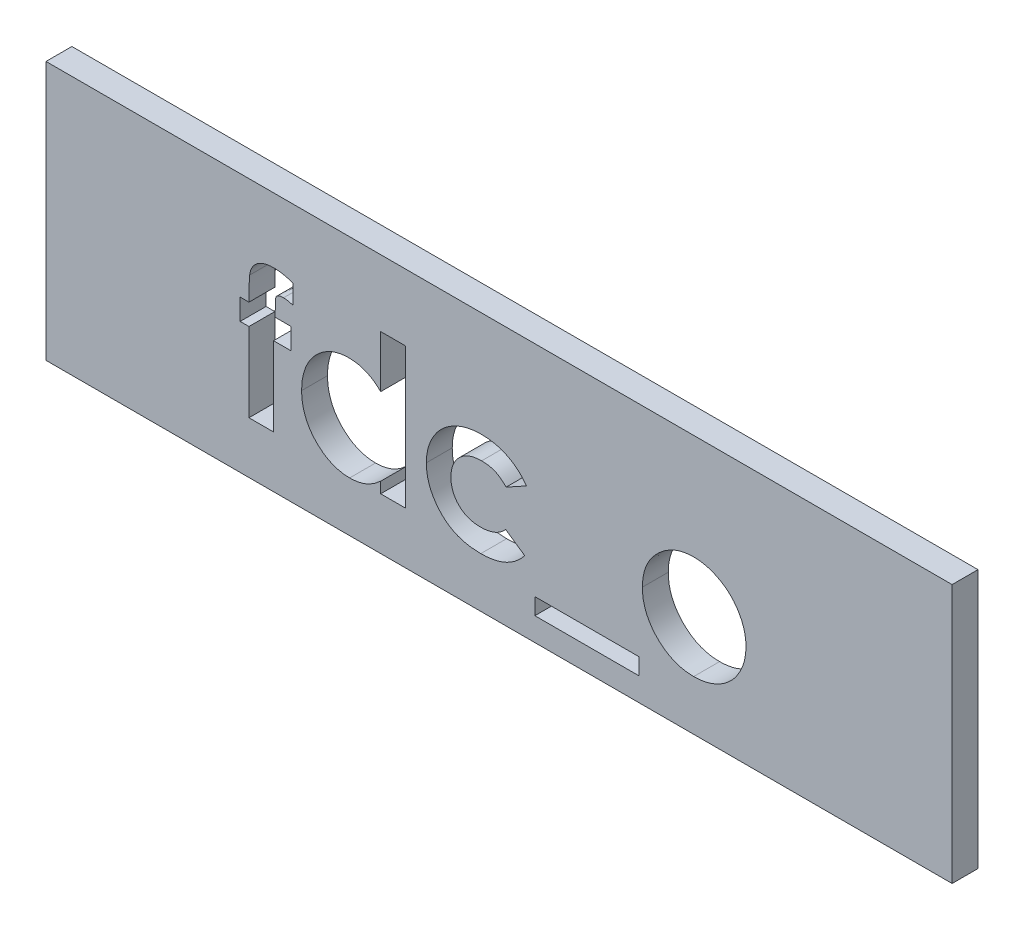
from build123d import *

# Parameters (mm, degrees)
ESQUISSE1_W             = 35
ESQUISSE1_H             = 10
BOSS_EXTRU_1_DEPTH      = 1
ESQUISSE2_R             = 1
BOSS_EXTRU_2_DEPTH      = 3
CHANFREIN1_SIZE         = 0.5
ESQUISSE3_W             = 3.731303419
ESQUISSE3_H             = 0.339209402
ENL_V_MAT_EXTRU_2_DEPTH = 1
ESQUISSE4_W             = 4.031303419
ESQUISSE4_H             = 0.639209402
ENL_V_MAT_EXTRU_3_DEPTH = 5


with BuildPart() as part:
    # Esquisse1 → Boss.-Extru.1 (new body)
    with BuildSketch(Plane.XY):
        with Locations((17.5, -5)):
            Rectangle(ESQUISSE1_W, ESQUISSE1_H)
    extrude(amount=BOSS_EXTRU_1_DEPTH)

    # Esquisse2 → Boss.-Extru.2 (add)
    with BuildSketch(Plane(origin=(0, 0, 0), x_dir=(-1, 0, 0), z_dir=(0, 0, -1))):
        with Locations(Location((-30, -5, 0), (0, 0, 180))):  # turned: the seam where the file's is
            Circle(ESQUISSE2_R)
        with Locations(Location((-5, -5, 0), (0, 0, 180))):  # turned: the seam where the file's is
            Circle(ESQUISSE2_R)
    extrude(amount=BOSS_EXTRU_2_DEPTH)

    # Chanfrein1
    chanfrein1_edges = [part.edges().sort_by_distance(p)[0] for p in [
        (29, -5, -3),
        (4, -5, -3),
    ]]
    chamfer(chanfrein1_edges, length=CHANFREIN1_SIZE)

    # Esquisse3 → Enlèv. mat.-Extru.2 (cut)
    with BuildSketch(Plane.XY.offset(1)):
        with BuildLine():
            Line((7.5, -4.133012821), (7.839209402, -4.133012821))
            add(Edge.make_bspline(
                [(7.839209402, -4.133012821), (7.839436087, -4.071529895), (7.839864718, -3.955274043), (7.842396141, -3.790623415), (7.844103204, -3.645738514), (7.847152395, -3.520641627), (7.851443807, -3.415699183), (7.855842957, -3.330916919), (7.859138216, -3.265759909), (7.863784094, -3.229146271), (7.865710136, -3.213967348)],
                knots=[0, 0, 0, 0, 1.604323161, 3.033556972, 4.296844687, 5.385167547, 6.298701784, 7.037230881, 7.60086462, 8, 8, 8, 8], degree=3))
            add(Edge.make_bspline(
                [(7.865710136, -3.213967348), (7.87474158, -3.161890377), (7.892346922, -3.060374738), (7.950626286, -2.918882495), (8.035310899, -2.795626552), (8.125081789, -2.708625992), (8.20827639, -2.649232911), (8.278069746, -2.610441166), (8.353957303, -2.577184782), (8.436184252, -2.551107791), (8.523968561, -2.529806224), (8.618257573, -2.514998431), (8.718533988, -2.506838038), (8.787567862, -2.505495261), (8.822916667, -2.504807692)],
                knots=[0, 0, 0, 0, 1.43722947, 2.801646624, 4.13175475, 5.486897933, 6.18427957, 6.91287343, 7.658885333, 8.438447905, 9.260561323, 10.118602268, 11.036630026, 12, 12, 12, 12], degree=3))
            add(Edge.make_bspline(
                [(8.822916667, -2.504807692), (8.877076848, -2.506497842), (8.989881613, -2.510018085), (9.163196958, -2.538477083), (9.347072447, -2.582043201), (9.470865215, -2.622584077), (9.53525641, -2.643671541)],
                knots=[0, 0, 0, 0, 0.891275659, 1.856347963, 2.884972697, 4, 4, 4, 4], degree=3))
            Line((9.53525641, -2.643671541), (9.53525641, -3.382512019))
            add(Edge.make_bspline(
                [(9.53525641, -3.382512019), (9.500719238, -3.372963073), (9.434849131, -3.354751099), (9.340072483, -3.33453419), (9.254675848, -3.322050298), (9.201027756, -3.319911685), (9.17590645, -3.318910256)],
                knots=[0, 0, 0, 0, 1.174725213, 2.24046353, 3.176077791, 4, 4, 4, 4], degree=3))
            add(Edge.make_bspline(
                [(9.17590645, -3.318910256), (9.148258685, -3.319492882), (9.096451036, -3.320584631), (9.024638093, -3.334473818), (8.963150903, -3.35634296), (8.931258279, -3.381319103), (8.916199252, -3.393112313)],
                knots=[0, 0, 0, 0, 1.199997209, 2.248609783, 3.173030359, 4, 4, 4, 4], degree=3))
            add(Edge.make_bspline(
                [(8.916199252, -3.393112313), (8.907086663, -3.404752874), (8.886953978, -3.430470677), (8.868654658, -3.482949523), (8.859364297, -3.549278153), (8.85773195, -3.598364775), (8.856837607, -3.625258747)],
                knots=[0, 0, 0, 0, 0.721105823, 1.593158367, 2.681320256, 4, 4, 4, 4], degree=3))
            Line((8.856837607, -3.625258747), (8.853657519, -4.133012821))
            Line((8.853657519, -4.133012821), (9.46741453, -4.133012821))
            Line((9.46741453, -4.133012821), (9.46741453, -4.947115385))
            Line((9.46741453, -4.947115385), (8.788995726, -4.947115385))
            Line((8.788995726, -4.947115385), (8.788995726, -8))
            Line((8.788995726, -8), (7.839209402, -8))
            Line((7.839209402, -8), (7.839209402, -4.947115385))
            Line((7.839209402, -4.947115385), (7.5, -4.947115385))
            Line((7.5, -4.947115385), (7.5, -4.133012821))
        make_face()
        with BuildLine():
            Line((12.927350427, -2.572649573), (13.877136752, -2.572649573))
            Line((13.877136752, -2.572649573), (13.877136752, -8))
            Line((13.877136752, -8), (12.927350427, -8))
            Line((12.927350427, -8), (12.927350427, -7.578108307))
            add(Edge.make_bspline(
                [(12.927350427, -7.578108307), (12.880288865, -7.619174794), (12.788951666, -7.698876735), (12.645033795, -7.802292031), (12.50069538, -7.887596284), (12.35524287, -7.955536469), (12.206440721, -8.005703304), (12.053217618, -8.042025263), (11.893366984, -8.063445212), (11.784702726, -8.066361058), (11.729517228, -8.06784188)],
                knots=[0, 0, 0, 0, 1.129196829, 2.191548051, 3.199897424, 4.157751732, 5.089409408, 6.034969131, 7.002052659, 8, 8, 8, 8], degree=3))
            add(Edge.make_bspline(
                [(11.729517228, -8.06784188), (11.667569052, -8.06644824), (11.545155948, -8.063694328), (11.365528306, -8.034704961), (11.19207996, -7.990330274), (11.024951702, -7.927534544), (10.864447606, -7.84616359), (10.709339329, -7.748340493), (10.562285899, -7.630631076), (10.422063147, -7.498128327), (10.293676037, -7.35237436), (10.181438813, -7.195392221), (10.086831175, -7.029408354), (10.0093242, -6.854973072), (9.948354954, -6.672214402), (9.904892607, -6.480552687), (9.879249772, -6.279919477), (9.876075911, -6.143255992), (9.874465812, -6.073926616)],
                knots=[0, 0, 0, 0, 0.980476535, 1.937477201, 2.874147792, 3.812856188, 4.758993464, 5.720109578, 6.712210464, 7.737600662, 8.772720504, 9.783789959, 10.789002326, 11.793715968, 12.802552247, 13.835794126, 14.902098527, 16, 16, 16, 16], degree=3))
            add(Edge.make_bspline(
                [(9.874465812, -6.073926616), (9.876155617, -6.002135956), (9.879470358, -5.861310578), (9.90371749, -5.654656032), (9.946377794, -5.458242081), (10.004548184, -5.271796664), (10.079374291, -5.09528757), (10.17050749, -4.928425622), (10.279187562, -4.771646968), (10.404422078, -4.627620093), (10.539644597, -4.495612504), (10.684308787, -4.380689431), (10.836152417, -4.283056932), (10.995336846, -4.203350925), (11.161839343, -4.141758156), (11.335002559, -4.096728813), (11.515595215, -4.069709626), (11.638616397, -4.0666964), (11.700896434, -4.06517094)],
                knots=[0, 0, 0, 0, 1.136281865, 2.228943489, 3.287578264, 4.313574083, 5.316051562, 6.317280042, 7.318008486, 8.329309503, 9.333984563, 10.305318864, 11.248632312, 12.186624717, 13.117503092, 14.05354244, 15.014596925, 16, 16, 16, 16], degree=3))
            add(Edge.make_bspline(
                [(11.700896434, -4.06517094), (11.758550736, -4.067000128), (11.872562121, -4.070617348), (12.040976575, -4.093386845), (12.203023264, -4.136259821), (12.360670242, -4.191498499), (12.511870158, -4.265830917), (12.657435343, -4.355121947), (12.797749337, -4.460505562), (12.883603923, -4.542000318), (12.927350427, -4.583525307)],
                knots=[0, 0, 0, 0, 1.011899165, 2.001030639, 2.974036179, 3.948778736, 4.92769327, 5.924124564, 6.942254589, 8, 8, 8, 8], degree=3))
            Line((12.927350427, -4.583525307), (12.927350427, -2.572649573))
        make_face()
        with BuildLine():
            Line((18.558226496, -4.921674679), (17.771684696, -5.354166667))
            add(Edge.make_bspline(
                [(17.771684696, -5.354166667), (17.735632486, -5.318063555), (17.666331076, -5.248664299), (17.555200694, -5.16081585), (17.446056067, -5.088079778), (17.334397613, -5.034404293), (17.219227237, -4.993981508), (17.096390884, -4.96720861), (16.964454838, -4.949579608), (16.873194524, -4.947953728), (16.826138488, -4.947115385)],
                knots=[0, 0, 0, 0, 1.150764855, 2.212059359, 3.192108068, 4.105322427, 5.000809612, 5.941206042, 6.938435785, 8, 8, 8, 8], degree=3))
            add(Edge.make_bspline(
                [(16.826138488, -4.947115385), (16.782984856, -4.948157704), (16.698536815, -4.950197436), (16.575144827, -4.965432834), (16.457873387, -4.989361835), (16.346933003, -5.024370047), (16.242521271, -5.0706178), (16.143774752, -5.12534506), (16.051653001, -5.190689399), (15.967458185, -5.265721963), (15.891457566, -5.348331153), (15.823661135, -5.436437405), (15.768119848, -5.531347754), (15.720100961, -5.630831462), (15.684796889, -5.736757056), (15.658967572, -5.848163371), (15.644245101, -5.965055344), (15.642112075, -6.044912531), (15.641025641, -6.085586939)],
                knots=[0, 0, 0, 0, 1.121765476, 2.195200973, 3.227634963, 4.230038321, 5.213228299, 6.192116585, 7.160777141, 8.14345191, 9.118668839, 10.075979138, 11.027630062, 11.972829041, 12.943187208, 13.923755399, 14.94248691, 16, 16, 16, 16], degree=3))
            add(Edge.make_bspline(
                [(15.641025641, -6.085586939), (15.642173552, -6.125199879), (15.64441493, -6.202546952), (15.658185201, -6.316188233), (15.682090908, -6.424369883), (15.717934388, -6.526519978), (15.760896806, -6.623580196), (15.814849737, -6.714778598), (15.878295413, -6.800513425), (15.951567847, -6.880039516), (16.032735111, -6.951563477), (16.120239785, -7.01472654), (16.213820792, -7.068277132), (16.314568258, -7.110302311), (16.420839596, -7.144544041), (16.533344489, -7.168925493), (16.651963215, -7.182458885), (16.732822598, -7.184733534), (16.774197049, -7.185897436)],
                knots=[0, 0, 0, 0, 1.070556293, 2.090336998, 3.088792742, 4.058148387, 5.011235098, 5.952916408, 6.915475435, 7.888633318, 8.869583867, 9.83422472, 10.800707077, 11.776204622, 12.778807041, 13.814557445, 14.881744048, 16, 16, 16, 16], degree=3))
            add(Edge.make_bspline(
                [(16.774197049, -7.185897436), (16.825138914, -7.184731737), (16.924570033, -7.182456462), (17.069114024, -7.163158313), (17.205127942, -7.131245961), (17.332626211, -7.08707673), (17.451430457, -7.029324638), (17.561235423, -6.958784767), (17.6631699, -6.875977477), (17.722612472, -6.811419049), (17.752604167, -6.778846154)],
                knots=[0, 0, 0, 0, 1.116373375, 2.178998604, 3.189797796, 4.174590301, 5.13072713, 6.078291395, 7.030403691, 8, 8, 8, 8], degree=3))
            Line((17.752604167, -6.778846154), (18.490384615, -7.285540198))
            add(Edge.make_bspline(
                [(18.490384615, -7.285540198), (18.439245218, -7.348064577), (18.338325507, -7.471451686), (18.162248596, -7.630493165), (17.972736656, -7.767145135), (17.765978195, -7.876219005), (17.544984298, -7.962973325), (17.30802811, -8.024300017), (17.055510426, -8.060400427), (16.882085723, -8.065321747), (16.793277577, -8.06784188)],
                knots=[0, 0, 0, 0, 0.997876357, 1.969233105, 2.924898516, 3.881013542, 4.852507933, 5.855329832, 6.901747111, 8, 8, 8, 8], degree=3))
            add(Edge.make_bspline(
                [(16.793277577, -8.06784188), (16.713344739, -8.06599407), (16.557227091, -8.062385093), (16.329689498, -8.034747141), (16.115678577, -7.988194771), (15.914754073, -7.923543097), (15.727099173, -7.839794971), (15.553322458, -7.735916003), (15.392251806, -7.614795726), (15.24679358, -7.475861975), (15.117011466, -7.324631087), (15.003711213, -7.165360916), (14.905723972, -7.000905122), (14.828853077, -6.828526399), (14.766028369, -6.650911564), (14.723598534, -6.465937483), (14.695613444, -6.275127813), (14.692709094, -6.145756539), (14.691239316, -6.080286792)],
                knots=[0, 0, 0, 0, 1.183377041, 2.311265848, 3.387807024, 4.421911742, 5.431260577, 6.423665966, 7.413571885, 8.409103097, 9.395976332, 10.359992013, 11.300391101, 12.225292883, 13.150239058, 14.085544813, 15.031169026, 16, 16, 16, 16], degree=3))
            add(Edge.make_bspline(
                [(14.691239316, -6.080286792), (14.692026687, -6.034673464), (14.693586226, -5.944327486), (14.706899759, -5.810153634), (14.727611143, -5.678256658), (14.758737908, -5.549562407), (14.797018334, -5.423446502), (14.843553376, -5.299934295), (14.900178546, -5.17966313), (14.963344096, -5.061609908), (15.03533523, -4.94889106), (15.113876066, -4.841556334), (15.198855943, -4.740263106), (15.291273163, -4.645955402), (15.390483332, -4.557958412), (15.495044193, -4.474486841), (15.608339284, -4.399845508), (15.72643003, -4.329668868), (15.850333661, -4.267198143), (15.978626075, -4.213277671), (16.110315856, -4.167464453), (16.24571866, -4.130629702), (16.384253309, -4.100271113), (16.527152518, -4.081004305), (16.673234037, -4.067462079), (16.772044831, -4.065939258), (16.821898371, -4.06517094)],
                knots=[0, 0, 0, 0, 1.00272354, 1.986087015, 2.96193297, 3.936200312, 4.894695956, 5.858592327, 6.835334787, 7.815655071, 8.800643866, 9.773423113, 10.738352213, 11.705312252, 12.673769326, 13.65298065, 14.64420052, 15.654211674, 16.672258995, 17.692438602, 18.712115155, 19.735602823, 20.776372304, 21.827874031, 22.90408564, 24, 24, 24, 24], degree=3))
            add(Edge.make_bspline(
                [(16.821898371, -4.06517094), (16.868205913, -4.065694486), (16.959534179, -4.06672703), (17.094405382, -4.07752371), (17.225597573, -4.095862345), (17.353334017, -4.120123587), (17.478002646, -4.150187491), (17.597932572, -4.190261668), (17.714763437, -4.235744349), (17.865242826, -4.304418449), (18.042630484, -4.406925659), (18.237354607, -4.553943595), (18.410974735, -4.725933137), (18.508881689, -4.856080703), (18.558226496, -4.921674679)],
                knots=[0, 0, 0, 0, 0.826738014, 1.630502179, 2.413926014, 3.191023582, 3.95155221, 4.701751672, 5.446919844, 6.189438973, 7.653650558, 9.094719814, 10.535747635, 12, 12, 12, 12], degree=3))
        make_face()
        with Locations((20.898771368, -8.780181624)):
            Rectangle(ESQUISSE3_W, ESQUISSE3_H)
        with BuildLine():
            add(Edge.make_bspline(
                [(25.013805422, -4.06517094), (25.058709486, -4.065970039), (25.147639879, -4.067552616), (25.280090591, -4.080726126), (25.410225758, -4.102219251), (25.538793382, -4.130049096), (25.66459959, -4.169042871), (25.788304223, -4.215809874), (25.911013355, -4.269503864), (26.029681371, -4.333418492), (26.145165559, -4.402739736), (26.254651442, -4.479206755), (26.357229816, -4.562218928), (26.454804883, -4.649851552), (26.54282949, -4.745919865), (26.626928879, -4.845794894), (26.702559366, -4.953054811), (26.772582303, -5.065085941), (26.834923219, -5.18124043), (26.88905484, -5.300710266), (26.936035998, -5.421843694), (26.972821303, -5.546116201), (27.003276145, -5.67188909), (27.022495315, -5.800703613), (27.036158812, -5.931236522), (27.037690923, -6.019122018), (27.038461538, -6.063326322)],
                knots=[0, 0, 0, 0, 1.022364134, 2.024744242, 3.027414945, 4.024939316, 5.017584196, 6.023349371, 7.035562955, 8.064994934, 9.090267829, 10.101425541, 11.102933353, 12.093946398, 13.084502048, 14.067315274, 15.065326281, 16.070028806, 17.074376865, 18.064572984, 19.055292013, 20.030201733, 21.013838017, 21.999348303, 22.993720005, 24, 24, 24, 24], degree=3))
            add(Edge.make_bspline(
                [(27.038461538, -6.063326322), (27.037648282, -6.107875973), (27.036031343, -6.196450777), (27.022989643, -6.328211509), (27.00141425, -6.457631787), (26.973477593, -6.585474047), (26.934629743, -6.710102427), (26.889240178, -6.833353996), (26.833522701, -6.953548791), (26.771922924, -7.071998023), (26.70144977, -7.185216092), (26.625884749, -7.293550495), (26.54213761, -7.394159111), (26.454817665, -7.490162093), (26.359783133, -7.57831305), (26.258550941, -7.660043319), (26.15199748, -7.736352088), (26.039356518, -7.805449009), (25.922070797, -7.866162011), (25.80211832, -7.920899736), (25.67879767, -7.9664728), (25.552364066, -8.003636379), (25.422740832, -8.032411209), (25.29021414, -8.051958292), (25.155069405, -8.065553064), (25.064014205, -8.06707403), (25.01804554, -8.06784188)],
                knots=[0, 0, 0, 0, 1.012026251, 2.012137606, 3.004615893, 3.992048833, 4.982446996, 5.968083444, 6.973977695, 7.990229942, 8.999482246, 10.001782172, 10.988562221, 11.971415814, 12.948383116, 13.930088534, 14.925840678, 15.924049238, 16.929462851, 17.924729459, 18.917889337, 19.913673841, 20.916777188, 21.931792057, 22.95587778, 24, 24, 24, 24], degree=3))
            add(Edge.make_bspline(
                [(25.01804554, -8.06784188), (24.950829978, -8.065868971), (24.818347081, -8.061980337), (24.623231098, -8.03534421), (24.435789046, -7.989496451), (24.255715492, -7.925585687), (24.082776516, -7.843686424), (23.918481391, -7.742323649), (23.761195828, -7.623492905), (23.613644131, -7.488198559), (23.478466789, -7.339768411), (23.360373116, -7.181320132), (23.260102031, -7.015228595), (23.177743748, -6.841304401), (23.114179948, -6.659309053), (23.068276039, -6.469786652), (23.041607346, -6.272204479), (23.0377516, -6.137961452), (23.035790598, -6.069686498)],
                knots=[0, 0, 0, 0, 1.029999031, 2.030143771, 3.011211297, 3.982305373, 4.953580601, 5.938004764, 6.935448627, 7.970290061, 9.001484052, 10.007591832, 10.993831261, 11.969999897, 12.951306496, 13.942897864, 14.953773953, 16, 16, 16, 16], degree=3))
            add(Edge.make_bspline(
                [(23.035790598, -6.069686498), (23.037819986, -5.996783815), (23.041808708, -5.85349505), (23.073480913, -5.643573745), (23.124058007, -5.442584044), (23.19665824, -5.251088178), (23.289398652, -5.068732961), (23.402613678, -4.895902998), (23.536862833, -4.732559142), (23.639670803, -4.633763179), (23.691948785, -4.583525307)],
                knots=[0, 0, 0, 0, 1.043912699, 2.05178951, 3.033892, 4.007821512, 4.978932272, 5.95884105, 6.962068106, 8, 8, 8, 8], degree=3))
            add(Edge.make_bspline(
                [(23.691948785, -4.583525307), (23.739919059, -4.541883762), (23.834554479, -4.459733615), (23.988305891, -4.35553962), (24.145729987, -4.265547797), (24.308713563, -4.19155778), (24.477710975, -4.135770502), (24.651856207, -4.095162354), (24.831113048, -4.07021964), (24.95259849, -4.066862392), (25.013805422, -4.06517094)],
                knots=[0, 0, 0, 0, 1.048115528, 2.067714963, 3.060638214, 4.039924844, 5.017819947, 5.994373833, 6.98952318, 8, 8, 8, 8], degree=3))
        make_face()
    extrude(amount=-ENL_V_MAT_EXTRU_2_DEPTH, mode=Mode.SUBTRACT)

    # Esquisse4 → Enlèv. mat.-Extru.3 (cut, through all)
    with BuildSketch(Plane.XY.offset(1)):
        with Locations((20.898771368, -8.780181624)):
            Rectangle(ESQUISSE4_W, ESQUISSE4_H)
    extrude(amount=-ENL_V_MAT_EXTRU_3_DEPTH, mode=Mode.SUBTRACT)


solid = part.part
